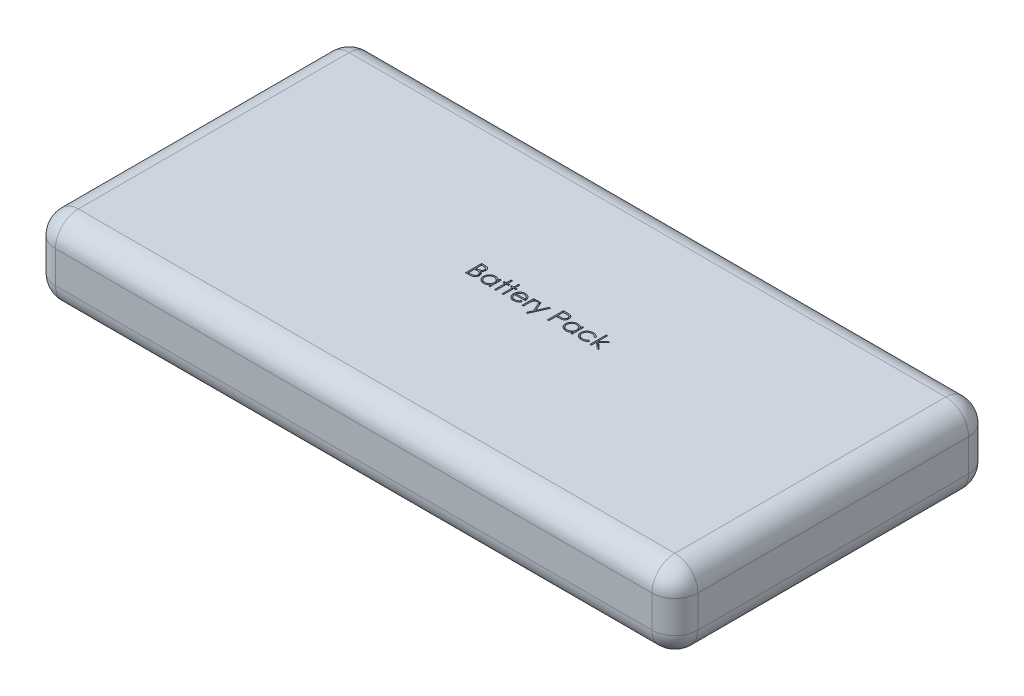
from build123d import *

# Parameters (mm, degrees)
SKETCH1_W           = 140
SKETCH1_H           = 69
BOSS_EXTRUDE1_DEPTH = 17
FILLET1_R           = 5
CUT_EXTRUDE1_DEPTH  = 1


with BuildPart() as part:
    # Sketch1 → Boss-Extrude1 (new body)
    with BuildSketch(Plane(origin=(0, 0, 0), x_dir=(1, 0, 0), z_dir=(0, 1, 0))):
        Rectangle(SKETCH1_W, SKETCH1_H)
    extrude(amount=BOSS_EXTRUDE1_DEPTH)

    # Fillet1
    fillet1_edges = [part.edges().sort_by_distance(p)[0] for p in [
        (-70, 17, 0),
        (0, 17, 34.5),
        (70, 17, 0),
        (0, 0, 34.5),
        (-70, 0, 0),
        (0, 0, -34.5),
        (70, 0, 0),
        (70, 8.5, 34.5),
        (-70, 8.5, 34.5),
        (-70, 8.5, -34.5),
        (70, 8.5, -34.5),
        (0, 17, -34.5),
    ]]
    fillet(fillet1_edges, radius=FILLET1_R)

    # Sketch2 → Cut-Extrude1 (cut)
    with BuildSketch(Plane(origin=(0, 17, 0), x_dir=(1, 0, 0), z_dir=(0, 1, 0))):
        with BuildLine():
            Line((-10.762481658, 4.15097288), (-10.07958903, 4.15097288))
            add(Edge.make_bspline(
                [(-10.07958903, 4.15097288), (-10.046160552, 4.15079713), (-9.981367841, 4.150456482), (-9.8871484, 4.145173351), (-9.798899589, 4.137969681), (-9.716595817, 4.126539588), (-9.640275114, 4.112747811), (-9.569707477, 4.096045995), (-9.505117305, 4.076019381), (-9.428004568, 4.0441731), (-9.340083907, 3.996849932), (-9.244885515, 3.926921367), (-9.163481275, 3.841388904), (-9.093294958, 3.744906248), (-9.037493839, 3.638770476), (-8.997124541, 3.525511288), (-8.971566666, 3.406589546), (-8.968938232, 3.324946368), (-8.967609863, 3.28368522)],
                knots=[0, 0, 0, 0, 0.00010027, 0.000194349, 0.000283026, 0.000365821, 0.000443519, 0.000515622, 0.000583254, 0.00064614, 0.000765662, 0.000881909, 0.000998927, 0.001118415, 0.001238844, 0.00135727, 0.001478274, 0.001601912, 0.001601912, 0.001601912, 0.001601912], degree=3))
            add(Edge.make_bspline(
                [(-8.967609863, 3.28368522), (-8.968703082, 3.245032664), (-8.970851359, 3.169076747), (-8.991394118, 3.057982638), (-9.023554787, 2.952231419), (-9.068260036, 2.852209034), (-9.126362032, 2.760175421), (-9.195220351, 2.675388155), (-9.278297153, 2.601437098), (-9.340540393, 2.560094195), (-9.372157139, 2.539093874)],
                knots=[0, 0, 0, 0, 0.000115857, 0.00022767, 0.000337672, 0.000446877, 0.000555233, 0.000663318, 0.000773539, 0.000887324, 0.000887324, 0.000887324, 0.000887324], degree=3))
            add(Edge.make_bspline(
                [(-9.372157139, 2.539093874), (-9.332396711, 2.523828875), (-9.256325164, 2.494623151), (-9.151639152, 2.442987687), (-9.061444307, 2.386825576), (-8.985047161, 2.325493726), (-8.919709506, 2.259384915), (-8.862656564, 2.187529801), (-8.81397519, 2.108991043), (-8.772262266, 2.024587508), (-8.73971351, 1.935181039), (-8.715337606, 1.841610263), (-8.701370157, 1.744210708), (-8.699382516, 1.677925329), (-8.698379094, 1.644462464)],
                knots=[0, 0, 0, 0, 0.000127722, 0.000244363, 0.000349599, 0.000445847, 0.000537565, 0.000627901, 0.000720503, 0.000814257, 0.000909859, 0.001005428, 0.001103887, 0.001204268, 0.001204268, 0.001204268, 0.001204268], degree=3))
            add(Edge.make_bspline(
                [(-8.698379094, 1.644462464), (-8.69935594, 1.610295592), (-8.701277912, 1.543071314), (-8.715457884, 1.444316179), (-8.739466991, 1.349941232), (-8.772538137, 1.25933605), (-8.815700452, 1.172675915), (-8.868228416, 1.089862651), (-8.93085998, 1.011728321), (-9.000922849, 0.937404697), (-9.080184994, 0.87057691), (-9.165700749, 0.811061203), (-9.258547069, 0.762115141), (-9.357199063, 0.72099912), (-9.462763379, 0.689591921), (-9.574765986, 0.667619347), (-9.693110288, 0.65281431), (-9.774320039, 0.651597106), (-9.815967235, 0.65097288)],
                knots=[0, 0, 0, 0, 0.000102481, 0.000201635, 0.000298562, 0.000394165, 0.000490425, 0.000588455, 0.000687769, 0.000790423, 0.000894381, 0.000998232, 0.001102369, 0.001208616, 0.001318415, 0.001432129, 0.001550749, 0.00167562, 0.00167562, 0.00167562, 0.00167562], degree=3))
            Line((-9.815967235, 0.65097288), (-10.762481658, 0.65097288))
            Line((-10.762481658, 0.65097288), (-10.762481658, 4.15097288))
        make_face()
        with BuildLine():
            Line((-10.448379094, 3.791998521), (-10.448379094, 2.67020365))
            Line((-10.448379094, 2.67020365), (-10.237341434, 2.67020365))
            add(Edge.make_bspline(
                [(-10.237341434, 2.67020365), (-10.206492638, 2.670603573), (-10.146886479, 2.671376305), (-10.060566583, 2.673589822), (-9.980441564, 2.679787866), (-9.906649731, 2.685984128), (-9.839307287, 2.696058716), (-9.778563426, 2.708050838), (-9.723464829, 2.720733744), (-9.659925283, 2.74230323), (-9.587852335, 2.774180906), (-9.511019231, 2.823652742), (-9.443284761, 2.882577095), (-9.386087574, 2.950568057), (-9.339276103, 3.025434243), (-9.306762388, 3.105981123), (-9.284715104, 3.190201255), (-9.282723572, 3.248019508), (-9.281712427, 3.277375124)],
                knots=[0, 0, 0, 0, 9.2559e-05, 0.000178842, 0.000258967, 0.000333616, 0.000400942, 0.000463093, 0.000519379, 0.000570374, 0.000664201, 0.000755025, 0.000843472, 0.000932526, 0.001020669, 0.001107124, 0.001192318, 0.001280185, 0.001280185, 0.001280185, 0.001280185], degree=3))
            add(Edge.make_bspline(
                [(-9.281712427, 3.277375124), (-9.282238608, 3.296800896), (-9.283270767, 3.334906668), (-9.29172407, 3.390456022), (-9.306091645, 3.442699774), (-9.324545938, 3.492353885), (-9.350334626, 3.537865735), (-9.38069809, 3.580808931), (-9.41738378, 3.619721049), (-9.459141093, 3.656090547), (-9.507149716, 3.688335075), (-9.561381007, 3.716575838), (-9.622568684, 3.739316615), (-9.689681539, 3.759232767), (-9.763752627, 3.773221061), (-9.84392718, 3.784874449), (-9.930861899, 3.790807191), (-9.991007002, 3.791592554), (-10.022097043, 3.791998521)],
                knots=[0, 0, 0, 0, 5.8261e-05, 0.000114285, 0.000168029, 0.000220632, 0.000272728, 0.000324483, 0.000378062, 0.000432741, 0.000490301, 0.000551137, 0.000615721, 0.000685833, 0.000760908, 0.00084162, 0.000928788, 0.00102206, 0.00102206, 0.00102206, 0.00102206], degree=3))
            Line((-10.022097043, 3.791998521), (-10.448379094, 3.791998521))
        make_face(mode=Mode.SUBTRACT)
        with BuildLine():
            Line((-10.448379094, 2.311229291), (-10.448379094, 1.009947239))
            Line((-10.448379094, 1.009947239), (-10.001063389, 1.009947239))
            add(Edge.make_bspline(
                [(-10.001063389, 1.009947239), (-9.969044463, 1.010330987), (-9.907332204, 1.011070609), (-9.818230974, 1.013485164), (-9.735647871, 1.01897744), (-9.659959735, 1.027623289), (-9.590349282, 1.037001738), (-9.527651579, 1.049613019), (-9.471358386, 1.06406198), (-9.406084078, 1.086396152), (-9.33258057, 1.121092623), (-9.253369713, 1.173406849), (-9.182943495, 1.235730157), (-9.123138236, 1.307861071), (-9.074125247, 1.386292398), (-9.038469792, 1.469437748), (-9.016478936, 1.555923276), (-9.013816766, 1.614889988), (-9.012481658, 1.644462464)],
                knots=[0, 0, 0, 0, 9.6064e-05, 0.000185151, 0.000267373, 0.000344257, 0.000413665, 0.000478015, 0.000536005, 0.000587888, 0.000684801, 0.000778918, 0.000871787, 0.000965866, 0.001059062, 0.00114827, 0.001236355, 0.001324974, 0.001324974, 0.001324974, 0.001324974], degree=3))
            add(Edge.make_bspline(
                [(-9.012481658, 1.644462464), (-9.012757763, 1.662955804), (-9.013305518, 1.699644186), (-9.021566133, 1.753560005), (-9.033580002, 1.805785879), (-9.049111436, 1.856463619), (-9.071730903, 1.904676995), (-9.098137448, 1.951379555), (-9.12909885, 1.996633034), (-9.177343016, 2.053845288), (-9.247515, 2.119762301), (-9.347221776, 2.184299803), (-9.460594074, 2.23634761), (-9.542821567, 2.258447086), (-9.585298165, 2.269863105)],
                knots=[0, 0, 0, 0, 5.5429e-05, 0.000109963, 0.000163198, 0.000216191, 0.000268588, 0.000322593, 0.000377046, 0.000432793, 0.000546889, 0.000664343, 0.000787646, 0.000919405, 0.000919405, 0.000919405, 0.000919405], degree=3))
            add(Edge.make_bspline(
                [(-9.585298165, 2.269863105), (-9.60232726, 2.273318189), (-9.639249853, 2.280809523), (-9.699457433, 2.288717227), (-9.768193302, 2.295762287), (-9.845616179, 2.300973444), (-9.93182402, 2.306359988), (-10.027000939, 2.308454809), (-10.130758254, 2.310954069), (-10.202750626, 2.311135203), (-10.240145921, 2.311229291)],
                knots=[0, 0, 0, 0, 5.2115e-05, 0.000112995, 0.000182062, 0.000259389, 0.000345767, 0.00044116, 0.000544948, 0.000657129, 0.000657129, 0.000657129, 0.000657129], degree=3))
            Line((-10.240145921, 2.311229291), (-10.448379094, 2.311229291))
        make_face(mode=Mode.SUBTRACT)
        with BuildLine():
            Line((-5.467609863, 3.208665188), (-5.467609863, 0.65097288))
            Line((-5.467609863, 0.65097288), (-5.781712427, 0.65097288))
            Line((-5.781712427, 0.65097288), (-5.781712427, 1.093380733))
            add(Edge.make_bspline(
                [(-5.781712427, 1.093380733), (-5.817131218, 1.053341139), (-5.886251433, 0.975203368), (-6.001692551, 0.873121195), (-6.124060729, 0.788742874), (-6.25276205, 0.720592958), (-6.387680294, 0.669400902), (-6.528516381, 0.633014743), (-6.675327762, 0.609620908), (-6.775580117, 0.607284886), (-6.826383902, 0.606101086)],
                knots=[0, 0, 0, 0, 0.000160263, 0.000312755, 0.000460949, 0.000605216, 0.000748578, 0.000892786, 0.001041028, 0.001193333, 0.001193333, 0.001193333, 0.001193333], degree=3))
            add(Edge.make_bspline(
                [(-6.826383902, 0.606101086), (-6.871551856, 0.607327458), (-6.96062506, 0.609745918), (-7.091654138, 0.628508222), (-7.217746387, 0.658638843), (-7.33902096, 0.700539733), (-7.454693105, 0.756120555), (-7.565753202, 0.822661803), (-7.671625894, 0.901902633), (-7.770697433, 0.992490661), (-7.861929433, 1.090885648), (-7.941990706, 1.195831195), (-8.008743786, 1.306873499), (-8.064563866, 1.422606653), (-8.107560211, 1.543921572), (-8.137533845, 1.67039874), (-8.156274292, 1.801888614), (-8.158691752, 1.891428137), (-8.159917556, 1.936830252)],
                knots=[0, 0, 0, 0, 0.000135464, 0.00026714, 0.000396211, 0.000523931, 0.000651257, 0.000780517, 0.000911767, 0.001047265, 0.00118272, 0.001313831, 0.001442491, 0.001570752, 0.001698704, 0.001827775, 0.001960146, 0.00209631, 0.00209631, 0.00209631, 0.00209631], degree=3))
            add(Edge.make_bspline(
                [(-8.159917556, 1.936830252), (-8.158664584, 1.981293956), (-8.156187527, 2.069196299), (-8.137734308, 2.198474997), (-8.106703299, 2.322993258), (-8.063155451, 2.442350201), (-8.007313496, 2.556690251), (-7.939385409, 2.666094276), (-7.859366285, 2.770863674), (-7.767113878, 2.8685349), (-7.667179107, 2.958755515), (-7.560270376, 3.03716456), (-7.449047095, 3.104881409), (-7.331784085, 3.158534885), (-7.21021698, 3.20194399), (-7.083263534, 3.231976958), (-6.951451955, 3.249674279), (-6.861961463, 3.252237043), (-6.816568197, 3.253536983)],
                knots=[0, 0, 0, 0, 0.000133363, 0.00026365, 0.000390846, 0.000517716, 0.000644083, 0.000771912, 0.000903449, 0.001038867, 0.001174416, 0.001306792, 0.001436052, 0.00156435, 0.001692963, 0.001822716, 0.001954992, 0.002091156, 0.002091156, 0.002091156, 0.002091156], degree=3))
            add(Edge.make_bspline(
                [(-6.816568197, 3.253536983), (-6.764368338, 3.252099231), (-6.662006878, 3.249279869), (-6.512278868, 3.225817141), (-6.37063439, 3.186178674), (-6.235980038, 3.132261176), (-6.108799352, 3.060612447), (-5.990296368, 2.970232486), (-5.879230885, 2.861691299), (-5.814850593, 2.778320854), (-5.781712427, 2.735407977)],
                knots=[0, 0, 0, 0, 0.00015654, 0.000306968, 0.000453261, 0.000596998, 0.000741098, 0.000889738, 0.001042937, 0.001205434, 0.001205434, 0.001205434, 0.001205434], degree=3))
            Line((-5.781712427, 2.735407977), (-5.781712427, 3.208665188))
            Line((-5.781712427, 3.208665188), (-5.467609863, 3.208665188))
        make_face()
        with BuildLine():
            add(Edge.make_bspline(
                [(-6.812361466, 2.939434419), (-6.858275804, 2.937800781), (-6.948903404, 2.93457624), (-7.081947406, 2.909402745), (-7.20926082, 2.867518151), (-7.330206894, 2.810236249), (-7.442875111, 2.738207513), (-7.543568782, 2.651086129), (-7.633111483, 2.551249115), (-7.708419747, 2.439147005), (-7.769810244, 2.318968914), (-7.812977276, 2.193344476), (-7.841446523, 2.064539498), (-7.844355044, 1.977176812), (-7.845814992, 1.933324643)],
                knots=[0, 0, 0, 0, 0.000137677, 0.000271753, 0.000404561, 0.000538791, 0.000672205, 0.000804452, 0.00093703, 0.001073348, 0.00120849, 0.001340643, 0.001470999, 0.001602378, 0.001602378, 0.001602378, 0.001602378], degree=3))
            add(Edge.make_bspline(
                [(-7.845814992, 1.933324643), (-7.843950098, 1.889734536), (-7.840227621, 1.80272518), (-7.813476927, 1.673744603), (-7.768597054, 1.548090561), (-7.707354991, 1.426829568), (-7.630668366, 1.314245467), (-7.541779714, 1.212505345), (-7.439829432, 1.125015757), (-7.326901925, 1.051778183), (-7.206293955, 0.992615662), (-7.079460023, 0.951450023), (-6.948784385, 0.924872242), (-6.859932051, 0.921767765), (-6.815165953, 0.92020365)],
                knots=[0, 0, 0, 0, 0.000130727, 0.000260941, 0.000393327, 0.000530037, 0.000667328, 0.000800955, 0.000934191, 0.001068956, 0.001203792, 0.001335934, 0.001468075, 0.001602253, 0.001602253, 0.001602253, 0.001602253], degree=3))
            add(Edge.make_bspline(
                [(-6.815165953, 0.92020365), (-6.76971945, 0.921863614), (-6.679330864, 0.925165117), (-6.545892156, 0.950446382), (-6.416397193, 0.992215181), (-6.292609965, 1.050114308), (-6.177293834, 1.121871663), (-6.073795956, 1.205878754), (-5.986279988, 1.303581939), (-5.912087378, 1.410958392), (-5.853911961, 1.528670388), (-5.811535902, 1.654004579), (-5.786481996, 1.786965327), (-5.783324267, 1.877829254), (-5.781712427, 1.92421006)],
                knots=[0, 0, 0, 0, 0.000136278, 0.000271043, 0.000405851, 0.000543552, 0.000679927, 0.000812429, 0.000941985, 0.001072088, 0.00120284, 0.001334538, 0.001467925, 0.001607002, 0.001607002, 0.001607002, 0.001607002], degree=3))
            add(Edge.make_bspline(
                [(-5.781712427, 1.92421006), (-5.782672084, 1.95954789), (-5.784560991, 2.029103924), (-5.798991561, 2.131231441), (-5.821946487, 2.228965167), (-5.854292657, 2.322407856), (-5.896783942, 2.411042872), (-5.948031707, 2.495506632), (-6.008937157, 2.575359843), (-6.078519853, 2.649502914), (-6.154685056, 2.717129377), (-6.235279596, 2.777493617), (-6.321258343, 2.82708239), (-6.41117538, 2.868123662), (-6.505186715, 2.900782811), (-6.604057335, 2.922570505), (-6.706736322, 2.937530826), (-6.776782377, 2.938793207), (-6.812361466, 2.939434419)],
                knots=[0, 0, 0, 0, 0.000105983, 0.000208608, 0.000308773, 0.00040678, 0.000504626, 0.000603105, 0.000702667, 0.00080535, 0.000907651, 0.001007914, 0.001106881, 0.00120477, 0.001304102, 0.001404791, 0.00150811, 0.001614764, 0.001614764, 0.001614764, 0.001614764], degree=3))
        make_face(mode=Mode.SUBTRACT)
        Polygon((-4.435558581, 4.24071647), (-4.121456017, 4.24071647), (-4.121456017, 3.208665188), (-3.672738068, 3.208665188), (-3.672738068, 2.894562624), (-4.121456017, 2.894562624), (-4.121456017, 0.65097288), (-4.435558581, 0.65097288), (-4.435558581, 2.894562624), (-4.88427653, 2.894562624), (-4.88427653, 3.208665188), (-4.435558581, 3.208665188), align=None)
        Polygon((-2.820173966, 4.24071647), (-2.506071402, 4.24071647), (-2.506071402, 3.208665188), (-2.057353453, 3.208665188), (-2.057353453, 2.894562624), (-2.506071402, 2.894562624), (-2.506071402, 0.65097288), (-2.820173966, 0.65097288), (-2.820173966, 2.894562624), (-3.268891915, 2.894562624), (-3.268891915, 3.208665188), (-2.820173966, 3.208665188), align=None)
        with BuildLine():
            Line((0.580266739, 1.458665188), (0.859313214, 1.312130733))
            add(Edge.make_bspline(
                [(0.859313214, 1.312130733), (0.837076618, 1.272687402), (0.79381301, 1.195946299), (0.719412262, 1.090514438), (0.641420189, 0.995666723), (0.556316221, 0.913937068), (0.466646542, 0.842685683), (0.371913888, 0.780347859), (0.27162507, 0.727229338), (0.165775345, 0.68247681), (0.053475794, 0.648067316), (-0.065545722, 0.623763095), (-0.191517218, 0.608739827), (-0.277863398, 0.606994686), (-0.322077011, 0.606101086)],
                knots=[0, 0, 0, 0, 0.000135759, 0.000264133, 0.000386579, 0.000503597, 0.000617365, 0.000729763, 0.000843304, 0.000957371, 0.001074023, 0.001195027, 0.001321389, 0.001453992, 0.001453992, 0.001453992, 0.001453992], degree=3))
            add(Edge.make_bspline(
                [(-0.322077011, 0.606101086), (-0.371218988, 0.607248261), (-0.46708075, 0.609486068), (-0.606620497, 0.628778532), (-0.737999915, 0.660250891), (-0.861211619, 0.704216432), (-0.975953871, 0.761643756), (-1.082454726, 0.831603238), (-1.181274252, 0.913735493), (-1.269298461, 1.008751936), (-1.348542344, 1.110433894), (-1.418468164, 1.216389778), (-1.476925595, 1.326353003), (-1.524478205, 1.439623527), (-1.56288307, 1.55548742), (-1.589649774, 1.674998888), (-1.605079522, 1.797834472), (-1.607443967, 1.880931808), (-1.608635504, 1.922807816)],
                knots=[0, 0, 0, 0, 0.000147371, 0.000287478, 0.000421649, 0.000552053, 0.000679042, 0.000805636, 0.000933558, 0.00106351, 0.001193382, 0.001319977, 0.001443869, 0.001566405, 0.001688128, 0.001809576, 0.001933238, 0.002058864, 0.002058864, 0.002058864, 0.002058864], degree=3))
            add(Edge.make_bspline(
                [(-1.608635504, 1.922807816), (-1.607576363, 1.962102647), (-1.605477285, 2.039979811), (-1.592246497, 2.155245356), (-1.568798204, 2.267273808), (-1.53662188, 2.376158256), (-1.495070634, 2.48171639), (-1.444238415, 2.584012454), (-1.384046037, 2.682937594), (-1.337573363, 2.745340728), (-1.31416435, 2.776774162)],
                knots=[0, 0, 0, 0, 0.000117891, 0.000233644, 0.000347498, 0.000460856, 0.000573868, 0.000687374, 0.000803169, 0.000920699, 0.000920699, 0.000920699, 0.000920699], degree=3))
            add(Edge.make_bspline(
                [(-1.31416435, 2.776774162), (-1.282456668, 2.814643033), (-1.220045721, 2.889181183), (-1.114489366, 2.987119509), (-1.000189169, 3.069163284), (-0.878577543, 3.13717042), (-0.748241069, 3.188844067), (-0.610931778, 3.227351649), (-0.465086192, 3.24892966), (-0.365380971, 3.251977494), (-0.314364671, 3.253536983)],
                knots=[0, 0, 0, 0, 0.000148071, 0.000291452, 0.00043058, 0.000569298, 0.000708346, 0.00085021, 0.000996268, 0.001149307, 0.001149307, 0.001149307, 0.001149307], degree=3))
            add(Edge.make_bspline(
                [(-0.314364671, 3.253536983), (-0.261917066, 3.252182934), (-0.15902682, 3.249526599), (-0.008994699, 3.224900265), (0.132966018, 3.185847711), (0.266798522, 3.13069392), (0.392516383, 3.059534369), (0.509302432, 2.971392527), (0.619153945, 2.86897444), (0.683062524, 2.79021123), (0.715583246, 2.750131534)],
                knots=[0, 0, 0, 0, 0.000157241, 0.00030847, 0.000454763, 0.000598116, 0.000741606, 0.000886879, 0.001036172, 0.001190853, 0.001190853, 0.001190853, 0.001190853], degree=3))
            add(Edge.make_bspline(
                [(0.715583246, 2.750131534), (0.737710184, 2.719927953), (0.781816777, 2.659721834), (0.837063877, 2.561550677), (0.885021272, 2.458840083), (0.923354233, 2.349929786), (0.954393734, 2.236110205), (0.976850553, 2.116567661), (0.990020172, 1.991337749), (0.992608869, 1.906011194), (0.993928598, 1.862511342)],
                knots=[0, 0, 0, 0, 0.000112234, 0.000223721, 0.000337279, 0.000451932, 0.000569628, 0.000690912, 0.000816421, 0.00094695, 0.00094695, 0.00094695, 0.00094695], degree=3))
            Line((0.993928598, 1.862511342), (-1.29453294, 1.862511342))
            add(Edge.make_bspline(
                [(-1.29453294, 1.862511342), (-1.292993334, 1.828810878), (-1.28996576, 1.762540274), (-1.275850617, 1.665569491), (-1.253601843, 1.573196149), (-1.22233278, 1.486113107), (-1.184465935, 1.403182979), (-1.138080218, 1.325020942), (-1.082740664, 1.251983012), (-1.021014965, 1.183415875), (-0.95230787, 1.122355113), (-0.880025122, 1.067703337), (-0.803131557, 1.02189774), (-0.722233474, 0.984717851), (-0.637461689, 0.955611535), (-0.548789494, 0.935743714), (-0.456391377, 0.922436607), (-0.393405643, 0.920956942), (-0.361339831, 0.92020365)],
                knots=[0, 0, 0, 0, 0.000101159, 0.000198924, 0.000293472, 0.000385722, 0.000476069, 0.000566611, 0.000657757, 0.000750573, 0.000842919, 0.000933083, 0.001022062, 0.001110842, 0.001199752, 0.001290403, 0.001383113, 0.001479259, 0.001479259, 0.001479259, 0.001479259], degree=3))
            add(Edge.make_bspline(
                [(-0.361339831, 0.92020365), (-0.329988684, 0.920811706), (-0.267781993, 0.922018207), (-0.175141135, 0.933750118), (-0.084001608, 0.952720394), (0.005259375, 0.978610384), (0.090830221, 1.010187236), (0.170075771, 1.048290094), (0.242955987, 1.09043984), (0.311072953, 1.138649516), (0.377143947, 1.197657703), (0.442686433, 1.271293424), (0.512963087, 1.358380951), (0.556952679, 1.423926617), (0.580266739, 1.458665188)],
                knots=[0, 0, 0, 0, 9.4016e-05, 0.000186545, 0.000279636, 0.000373054, 0.000465125, 0.000552934, 0.000636508, 0.000717442, 0.000802858, 0.000901616, 0.001012865, 0.001138311, 0.001138311, 0.001138311, 0.001138311], degree=3))
        make_face()
        with BuildLine():
            add(Edge.make_bspline(
                [(0.679826034, 2.176613906), (0.66832941, 2.21827678), (0.646202108, 2.2984644), (0.599965744, 2.409505291), (0.547894203, 2.508193192), (0.486272472, 2.593772825), (0.416453746, 2.669776338), (0.335808563, 2.736194923), (0.24537267, 2.795612374), (0.145613529, 2.845764874), (0.039971744, 2.888454732), (-0.070634448, 2.917079848), (-0.183492236, 2.93668939), (-0.259826522, 2.938515499), (-0.29823887, 2.939434419)],
                knots=[0, 0, 0, 0, 0.000129543, 0.000249328, 0.000360065, 0.000463575, 0.000564789, 0.000668832, 0.000776175, 0.000888744, 0.001003316, 0.001117263, 0.001230914, 0.001346035, 0.001346035, 0.001346035, 0.001346035], degree=3))
            add(Edge.make_bspline(
                [(-0.29823887, 2.939434419), (-0.329588308, 2.938822747), (-0.391559557, 2.937613601), (-0.482860625, 2.926143472), (-0.570540324, 2.907183627), (-0.655245612, 2.88121867), (-0.73586648, 2.846610068), (-0.814061249, 2.806026841), (-0.887841645, 2.756485258), (-0.93398294, 2.718726403), (-0.957293357, 2.699650765)],
                knots=[0, 0, 0, 0, 9.4016e-05, 0.000185849, 0.000275511, 0.000362884, 0.000451173, 0.00053836, 0.000626838, 0.000717174, 0.000717174, 0.000717174, 0.000717174], degree=3))
            add(Edge.make_bspline(
                [(-0.957293357, 2.699650765), (-0.973986639, 2.684556449), (-1.007769773, 2.654009233), (-1.052910295, 2.601380027), (-1.096130767, 2.544628465), (-1.13546442, 2.48158334), (-1.171542006, 2.412962561), (-1.205301984, 2.339344926), (-1.235688396, 2.260171796), (-1.252784506, 2.204999356), (-1.261580216, 2.176613906)],
                knots=[0, 0, 0, 0, 6.7454e-05, 0.00013651, 0.000207604, 0.000281328, 0.000359112, 0.000440057, 0.000524171, 0.000613305, 0.000613305, 0.000613305, 0.000613305], degree=3))
            Line((-1.261580216, 2.176613906), (0.679826034, 2.176613906))
        make_face(mode=Mode.SUBTRACT)
        with BuildLine():
            Line((1.532390137, 3.208665188), (1.846492701, 3.208665188))
            Line((1.846492701, 3.208665188), (1.846492701, 2.832162784))
            add(Edge.make_bspline(
                [(1.846492701, 2.832162784), (1.86968146, 2.867218613), (1.91402978, 2.934262612), (1.98774271, 3.022931913), (2.063246041, 3.096346959), (2.140901228, 3.154850478), (2.221279328, 3.198663597), (2.30261628, 3.230756632), (2.38619175, 3.249733947), (2.442353674, 3.252267606), (2.470491098, 3.253536983)],
                knots=[0, 0, 0, 0, 0.000126023, 0.000241017, 0.000345147, 0.000441342, 0.00053171, 0.000618946, 0.000702978, 0.000787349, 0.000787349, 0.000787349, 0.000787349], degree=3))
            add(Edge.make_bspline(
                [(2.470491098, 3.253536983), (2.492317425, 3.252346456), (2.53722651, 3.249896871), (2.6052091, 3.232686046), (2.675252552, 3.205208023), (2.720394939, 3.179367801), (2.743928598, 3.165896759)],
                knots=[0, 0, 0, 0, 6.5445e-05, 0.000134658, 0.00020926, 0.000290509, 0.000290509, 0.000290509, 0.000290509], degree=3))
            Line((2.743928598, 3.165896759), (2.571452637, 2.893861502))
            add(Edge.make_bspline(
                [(2.571452637, 2.893861502), (2.556343616, 2.900601768), (2.527663801, 2.913396084), (2.485709235, 2.928538094), (2.447027898, 2.93745401), (2.42238434, 2.938804727), (2.410895746, 2.939434419)],
                knots=[0, 0, 0, 0, 4.9621e-05, 9.4191e-05, 0.00013366, 0.000168129, 0.000168129, 0.000168129, 0.000168129], degree=3))
            add(Edge.make_bspline(
                [(2.410895746, 2.939434419), (2.385690012, 2.937754381), (2.334277622, 2.934327592), (2.258793123, 2.907388784), (2.185545917, 2.863863544), (2.127374255, 2.815592433), (2.082332002, 2.769044635), (2.050191777, 2.728396232), (2.02070903, 2.682817601), (1.992538809, 2.633087917), (1.966872515, 2.578358071), (1.942917846, 2.519174858), (1.921258983, 2.455469729), (1.908908739, 2.411087209), (1.902582444, 2.388352688)],
                knots=[0, 0, 0, 0, 7.549e-05, 0.000153978, 0.000237553, 0.000330197, 0.000379784, 0.000431685, 0.000485357, 0.000542493, 0.000603021, 0.000666557, 0.00073396, 0.000804745, 0.000804745, 0.000804745, 0.000804745], degree=3))
            add(Edge.make_bspline(
                [(1.902582444, 2.388352688), (1.897850051, 2.368075515), (1.887368159, 2.323163116), (1.877176621, 2.247814591), (1.867107103, 2.158790932), (1.860010485, 2.05584434), (1.853432443, 1.939231896), (1.849722361, 1.80877595), (1.84661922, 1.664342599), (1.846536153, 1.563368246), (1.846492701, 1.510548201)],
                knots=[0, 0, 0, 0, 6.2435e-05, 0.000138289, 0.000227871, 0.000331224, 0.000447781, 0.000578258, 0.000722716, 0.000881171, 0.000881171, 0.000881171, 0.000881171], degree=3))
            Line((1.846492701, 1.510548201), (1.846492701, 0.65097288))
            Line((1.846492701, 0.65097288), (1.532390137, 0.65097288))
            Line((1.532390137, 0.65097288), (1.532390137, 3.208665188))
        make_face()
        Polygon((2.788800393, 3.208665188), (3.12744222, 3.208665188), (3.993327637, 1.249730893), (4.872534367, 3.208665188), (5.211877316, 3.208665188), (3.641364496, -0.291334812), (3.302021547, -0.291334812), (3.822955041, 0.869021759), align=None)
        with BuildLine():
            Line((7.051620906, 4.15097288), (7.738019143, 4.15097288))
            add(Edge.make_bspline(
                [(7.738019143, 4.15097288), (7.785230049, 4.150920984), (7.875688242, 4.150821549), (8.005403298, 4.147806803), (8.123213029, 4.143780111), (8.22886341, 4.138198218), (8.322679508, 4.131601627), (8.404236808, 4.122349588), (8.474176364, 4.112689292), (8.516082814, 4.102867886), (8.535194624, 4.098388746)],
                knots=[0, 0, 0, 0, 0.000141628, 0.000271366, 0.00038923, 0.000495248, 0.00058876, 0.000671296, 0.000741499, 0.00080036, 0.00080036, 0.00080036, 0.00080036], degree=3))
            add(Edge.make_bspline(
                [(8.535194624, 4.098388746), (8.559388158, 4.091766796), (8.607205135, 4.078678934), (8.676106178, 4.052465211), (8.741660023, 4.021383046), (8.804091582, 3.985959106), (8.862633665, 3.944673542), (8.918159706, 3.899199924), (8.970179686, 3.848488355), (9.018401078, 3.793107615), (9.062685876, 3.733987406), (9.100815558, 3.670245176), (9.132742785, 3.602953872), (9.160126057, 3.532160301), (9.179834511, 3.457269978), (9.194681411, 3.378803265), (9.204105039, 3.296768575), (9.2050076, 3.240708707), (9.20546706, 3.212170797)],
                knots=[0, 0, 0, 0, 7.5216e-05, 0.00014866, 0.000220794, 0.000292713, 0.000363707, 0.000435434, 0.000507823, 0.000581364, 0.000655543, 0.000729131, 0.000803767, 0.000878771, 0.000956497, 0.001035702, 0.001118238, 0.001203821, 0.001203821, 0.001203821, 0.001203821], degree=3))
            add(Edge.make_bspline(
                [(9.20546706, 3.212170797), (9.205045635, 3.18339302), (9.204221089, 3.127087356), (9.194324804, 3.044714568), (9.180994612, 2.965996178), (9.16049756, 2.891106728), (9.133651887, 2.820490957), (9.102159834, 2.753069725), (9.064176303, 2.689990053), (9.020531474, 2.631022936), (8.971979879, 2.576113023), (8.918726941, 2.525658229), (8.860987649, 2.47995389), (8.798945501, 2.438897547), (8.731995652, 2.403441267), (8.661153498, 2.371683962), (8.585803282, 2.345012902), (8.533660768, 2.33098284), (8.507149752, 2.323849483)],
                knots=[0, 0, 0, 0, 8.6284e-05, 0.00016882, 0.000248587, 0.000325638, 0.000401297, 0.000474998, 0.000548586, 0.000621785, 0.0006948, 0.0007682, 0.000841564, 0.000915458, 0.000991056, 0.00106858, 0.00114819, 0.001230532, 0.001230532, 0.001230532, 0.001230532], degree=3))
            add(Edge.make_bspline(
                [(8.507149752, 2.323849483), (8.485222418, 2.319186502), (8.437167391, 2.308967308), (8.358024669, 2.297558851), (8.265879283, 2.28782125), (8.160857003, 2.280520113), (8.043052098, 2.274269744), (7.91240084, 2.26930165), (7.768646763, 2.266571796), (7.668375519, 2.266431004), (7.616023951, 2.266357496)],
                knots=[0, 0, 0, 0, 6.7238e-05, 0.000147357, 0.000239727, 0.000345177, 0.000463135, 0.000593636, 0.000737393, 0.000894446, 0.000894446, 0.000894446, 0.000894446], degree=3))
            Line((7.616023951, 2.266357496), (7.36572347, 2.266357496))
            Line((7.36572347, 2.266357496), (7.36572347, 0.65097288))
            Line((7.36572347, 0.65097288), (7.051620906, 0.65097288))
            Line((7.051620906, 0.65097288), (7.051620906, 4.15097288))
        make_face()
        with BuildLine():
            Line((7.36572347, 3.791998521), (7.36572347, 2.625331855))
            Line((7.36572347, 2.625331855), (7.978503919, 2.617619515))
            add(Edge.make_bspline(
                [(7.978503919, 2.617619515), (8.008423845, 2.617604051), (8.066183644, 2.617574199), (8.149619868, 2.621559423), (8.227029155, 2.626159955), (8.29817373, 2.632895879), (8.363085665, 2.642417136), (8.421873194, 2.652028874), (8.474080477, 2.665934237), (8.535179678, 2.684657306), (8.603263026, 2.716589922), (8.677330574, 2.762939812), (8.740101161, 2.82202052), (8.794419458, 2.888448351), (8.837525335, 2.962347481), (8.869081328, 3.041416417), (8.887622485, 3.124844267), (8.890108679, 3.181932406), (8.891364496, 3.210768553)],
                knots=[0, 0, 0, 0, 8.9746e-05, 0.000173253, 0.000250533, 0.00032239, 0.000387534, 0.00044736, 0.000500926, 0.000549486, 0.000638903, 0.000725641, 0.000810488, 0.000896226, 0.000982324, 0.00106604, 0.001150757, 0.001237226, 0.001237226, 0.001237226, 0.001237226], degree=3))
            add(Edge.make_bspline(
                [(8.891364496, 3.210768553), (8.890101849, 3.238907067), (8.887591864, 3.294842949), (8.868936001, 3.37682171), (8.837586687, 3.455057414), (8.794130093, 3.528030499), (8.741388963, 3.594219303), (8.68008962, 3.65171643), (8.610376358, 3.697938133), (8.545528127, 3.727771415), (8.487926941, 3.74598669), (8.437894981, 3.758731531), (8.381404307, 3.768907137), (8.318436527, 3.77714664), (8.249479693, 3.784200101), (8.173941379, 3.788986078), (8.092107735, 3.791787534), (8.035297164, 3.79192649), (8.005847669, 3.791998521)],
                knots=[0, 0, 0, 0, 8.4371e-05, 0.000167719, 0.000250783, 0.000336277, 0.000421575, 0.000503926, 0.000587348, 0.000671427, 0.000717102, 0.000768457, 0.000826213, 0.000889178, 0.000958942, 0.001034123, 0.001116202, 0.001204546, 0.001204546, 0.001204546, 0.001204546], degree=3))
            Line((8.005847669, 3.791998521), (7.36572347, 3.791998521))
        make_face(mode=Mode.SUBTRACT)
        with BuildLine():
            Line((12.436236291, 3.208665188), (12.436236291, 0.65097288))
            Line((12.436236291, 0.65097288), (12.122133726, 0.65097288))
            Line((12.122133726, 0.65097288), (12.122133726, 1.093380733))
            add(Edge.make_bspline(
                [(12.122133726, 1.093380733), (12.086714936, 1.053341139), (12.017594721, 0.975203368), (11.902153603, 0.873121195), (11.779785425, 0.788742874), (11.651084104, 0.720592958), (11.51616586, 0.669400902), (11.375329773, 0.633014743), (11.228518392, 0.609620908), (11.128266037, 0.607284886), (11.077462252, 0.606101086)],
                knots=[0, 0, 0, 0, 0.000160263, 0.000312755, 0.000460949, 0.000605216, 0.000748578, 0.000892786, 0.001041028, 0.001193333, 0.001193333, 0.001193333, 0.001193333], degree=3))
            add(Edge.make_bspline(
                [(11.077462252, 0.606101086), (11.032294298, 0.607327458), (10.943221093, 0.609745918), (10.812192016, 0.628508222), (10.686099767, 0.658638843), (10.564825194, 0.700539733), (10.449153049, 0.756120555), (10.338092952, 0.822661803), (10.23222026, 0.901902633), (10.133148721, 0.992490661), (10.041916721, 1.090885648), (9.961855448, 1.195831195), (9.895102368, 1.306873499), (9.839282287, 1.422606653), (9.796285943, 1.543921572), (9.766312309, 1.67039874), (9.747571862, 1.801888614), (9.745154401, 1.891428137), (9.743928598, 1.936830252)],
                knots=[0, 0, 0, 0, 0.000135464, 0.00026714, 0.000396211, 0.000523931, 0.000651257, 0.000780517, 0.000911767, 0.001047265, 0.00118272, 0.001313831, 0.001442491, 0.001570752, 0.001698704, 0.001827775, 0.001960146, 0.00209631, 0.00209631, 0.00209631, 0.00209631], degree=3))
            add(Edge.make_bspline(
                [(9.743928598, 1.936830252), (9.74518157, 1.981293956), (9.747658626, 2.069196299), (9.766111846, 2.198474997), (9.797142855, 2.322993258), (9.840690703, 2.442350201), (9.896532658, 2.556690251), (9.964460745, 2.666094276), (10.044479869, 2.770863674), (10.136732276, 2.8685349), (10.236667046, 2.958755515), (10.343575777, 3.03716456), (10.454799059, 3.104881409), (10.572062069, 3.158534885), (10.693629174, 3.20194399), (10.82058262, 3.231976958), (10.952394198, 3.249674279), (11.041884691, 3.252237043), (11.087277957, 3.253536983)],
                knots=[0, 0, 0, 0, 0.000133363, 0.00026365, 0.000390846, 0.000517716, 0.000644083, 0.000771912, 0.000903449, 0.001038867, 0.001174416, 0.001306792, 0.001436052, 0.00156435, 0.001692963, 0.001822716, 0.001954992, 0.002091156, 0.002091156, 0.002091156, 0.002091156], degree=3))
            add(Edge.make_bspline(
                [(11.087277957, 3.253536983), (11.139477816, 3.252099231), (11.241839276, 3.249279869), (11.391567286, 3.225817141), (11.533211763, 3.186178674), (11.667866115, 3.132261176), (11.795046802, 3.060612447), (11.913549786, 2.970232486), (12.024615269, 2.861691299), (12.088995561, 2.778320854), (12.122133726, 2.735407977)],
                knots=[0, 0, 0, 0, 0.00015654, 0.000306968, 0.000453261, 0.000596998, 0.000741098, 0.000889738, 0.001042937, 0.001205434, 0.001205434, 0.001205434, 0.001205434], degree=3))
            Line((12.122133726, 2.735407977), (12.122133726, 3.208665188))
            Line((12.122133726, 3.208665188), (12.436236291, 3.208665188))
        make_face()
        with BuildLine():
            add(Edge.make_bspline(
                [(11.091484688, 2.939434419), (11.04557035, 2.937800781), (10.95494275, 2.93457624), (10.821898748, 2.909402745), (10.694585334, 2.867518151), (10.57363926, 2.810236249), (10.460971043, 2.738207513), (10.360277372, 2.651086129), (10.270734671, 2.551249115), (10.195426407, 2.439147005), (10.13403591, 2.318968914), (10.090868878, 2.193344476), (10.06239963, 2.064539498), (10.05949111, 1.977176812), (10.058031162, 1.933324643)],
                knots=[0, 0, 0, 0, 0.000137677, 0.000271753, 0.000404561, 0.000538791, 0.000672205, 0.000804452, 0.00093703, 0.001073348, 0.00120849, 0.001340643, 0.001470999, 0.001602378, 0.001602378, 0.001602378, 0.001602378], degree=3))
            add(Edge.make_bspline(
                [(10.058031162, 1.933324643), (10.059896056, 1.889734536), (10.063618533, 1.80272518), (10.090369227, 1.673744603), (10.1352491, 1.548090561), (10.196491163, 1.426829568), (10.273177788, 1.314245467), (10.36206644, 1.212505345), (10.464016722, 1.125015757), (10.576944229, 1.051778183), (10.697552199, 0.992615662), (10.824386131, 0.951450023), (10.955061769, 0.924872242), (11.043914103, 0.921767765), (11.088680201, 0.92020365)],
                knots=[0, 0, 0, 0, 0.000130727, 0.000260941, 0.000393327, 0.000530037, 0.000667328, 0.000800955, 0.000934191, 0.001068956, 0.001203792, 0.001335934, 0.001468075, 0.001602253, 0.001602253, 0.001602253, 0.001602253], degree=3))
            add(Edge.make_bspline(
                [(11.088680201, 0.92020365), (11.134126704, 0.921863614), (11.22451529, 0.925165117), (11.357953998, 0.950446382), (11.487448961, 0.992215181), (11.611236189, 1.050114308), (11.72655232, 1.121871663), (11.830050198, 1.205878754), (11.917566166, 1.303581939), (11.991758776, 1.410958392), (12.049934193, 1.528670388), (12.092310252, 1.654004579), (12.117364158, 1.786965327), (12.120521887, 1.877829254), (12.122133726, 1.92421006)],
                knots=[0, 0, 0, 0, 0.000136278, 0.000271043, 0.000405851, 0.000543552, 0.000679927, 0.000812429, 0.000941985, 0.001072088, 0.00120284, 0.001334538, 0.001467925, 0.001607002, 0.001607002, 0.001607002, 0.001607002], degree=3))
            add(Edge.make_bspline(
                [(12.122133726, 1.92421006), (12.12117407, 1.95954789), (12.119285163, 2.029103924), (12.104854593, 2.131231441), (12.081899667, 2.228965167), (12.049553497, 2.322407856), (12.007062212, 2.411042872), (11.955814446, 2.495506632), (11.894908997, 2.575359843), (11.825326301, 2.649502914), (11.749161098, 2.717129377), (11.668566557, 2.777493617), (11.58258781, 2.82708239), (11.492670773, 2.868123662), (11.398659439, 2.900782811), (11.299788819, 2.922570505), (11.197109832, 2.937530826), (11.127063777, 2.938793207), (11.091484688, 2.939434419)],
                knots=[0, 0, 0, 0, 0.000105983, 0.000208608, 0.000308773, 0.00040678, 0.000504626, 0.000603105, 0.000702667, 0.00080535, 0.000907651, 0.001007914, 0.001106881, 0.00120477, 0.001304102, 0.001404791, 0.00150811, 0.001614764, 0.001614764, 0.001614764, 0.001614764], degree=3))
        make_face(mode=Mode.SUBTRACT)
        with BuildLine():
            Line((15.667005521, 2.654077848), (15.404084848, 2.49071647))
            add(Edge.make_bspline(
                [(15.404084848, 2.49071647), (15.375254983, 2.526544864), (15.318508288, 2.597066974), (15.219969051, 2.688076908), (15.114957637, 2.766243949), (15.001679589, 2.8299477), (14.880293789, 2.879169151), (14.751278938, 2.913999356), (14.614653433, 2.935703599), (14.520988234, 2.938170436), (14.472995105, 2.939434419)],
                knots=[0, 0, 0, 0, 0.0001378, 0.000271237, 0.000401088, 0.000529797, 0.000659994, 0.000793002, 0.000929944, 0.001073845, 0.001073845, 0.001073845, 0.001073845], degree=3))
            add(Edge.make_bspline(
                [(14.472995105, 2.939434419), (14.434636148, 2.938377577), (14.359089225, 2.936296155), (14.248183072, 2.923285661), (14.142540719, 2.899643653), (14.04150001, 2.868492696), (13.945779591, 2.826742406), (13.855128673, 2.77593265), (13.768743183, 2.71688261), (13.689126441, 2.648472065), (13.616297434, 2.574073397), (13.55319852, 2.494319702), (13.498261587, 2.41159981), (13.455155631, 2.323848068), (13.41988046, 2.233072015), (13.39667374, 2.137558159), (13.381209045, 2.038530152), (13.379439716, 1.971011812), (13.378543983, 1.936830252)],
                knots=[0, 0, 0, 0, 0.000115089, 0.000226664, 0.000334347, 0.000439455, 0.000543394, 0.000646972, 0.000750824, 0.000856758, 0.000961376, 0.00106266, 0.001161449, 0.00125865, 0.001355399, 0.001453007, 0.001552955, 0.001655437, 0.001655437, 0.001655437, 0.001655437], degree=3))
            add(Edge.make_bspline(
                [(13.378543983, 1.936830252), (13.380323235, 1.892061041), (13.383857766, 1.803125845), (13.411559225, 1.671847744), (13.456903633, 1.544924053), (13.518961483, 1.423255916), (13.597438618, 1.310661761), (13.689611181, 1.209678306), (13.795530264, 1.122262278), (13.914262595, 1.049789753), (14.043020338, 0.991528386), (14.180410443, 0.950021053), (14.325310224, 0.92496868), (14.424516971, 0.921812737), (14.47509847, 0.92020365)],
                knots=[0, 0, 0, 0, 0.000134224, 0.00026664, 0.000400581, 0.000537609, 0.000675117, 0.000811087, 0.000946551, 0.001085679, 0.001227203, 0.001369372, 0.001515181, 0.001666857, 0.001666857, 0.001666857, 0.001666857], degree=3))
            add(Edge.make_bspline(
                [(14.47509847, 0.92020365), (14.521453654, 0.921503147), (14.612553893, 0.924057004), (14.745721178, 0.945585967), (14.872501089, 0.980829601), (14.992889119, 1.029977251), (15.106665285, 1.093504767), (15.21309446, 1.171863937), (15.314294399, 1.262800538), (15.373791375, 1.333118509), (15.404084848, 1.368921598)],
                knots=[0, 0, 0, 0, 0.000138999, 0.00027317, 0.000403475, 0.000533023, 0.000662344, 0.000793326, 0.000928824, 0.001069379, 0.001069379, 0.001069379, 0.001069379], degree=3))
            Line((15.404084848, 1.368921598), (15.667005521, 1.196445637))
            add(Edge.make_bspline(
                [(15.667005521, 1.196445637), (15.651417819, 1.17355491), (15.620294152, 1.127849433), (15.568266527, 1.063405317), (15.512146695, 1.003083634), (15.452153598, 0.946965244), (15.389070588, 0.893707225), (15.320742679, 0.84585565), (15.249373067, 0.800720828), (15.17412391, 0.760107956), (15.095773212, 0.723601634), (15.014431222, 0.692210463), (14.930451409, 0.665240357), (14.843735033, 0.643803011), (14.754111135, 0.626692172), (14.6618115, 0.615338471), (14.566867919, 0.606863189), (14.502695767, 0.606357323), (14.470190617, 0.606101086)],
                knots=[0, 0, 0, 0, 8.3056e-05, 0.000165835, 0.000248187, 0.000330026, 0.000412165, 0.000495625, 0.000580051, 0.000665384, 0.00075196, 0.000839196, 0.00092678, 0.001016395, 0.001107013, 0.001200326, 0.001295291, 0.001392769, 0.001392769, 0.001392769, 0.001392769], degree=3))
            add(Edge.make_bspline(
                [(14.470190617, 0.606101086), (14.420579734, 0.606992365), (14.323342042, 0.60873928), (14.181019534, 0.627947756), (14.045005867, 0.656905372), (13.915347509, 0.698469106), (13.792024275, 0.751973881), (13.675151156, 0.817330796), (13.565115138, 0.895082586), (13.463004355, 0.983845355), (13.369222909, 1.080085996), (13.288696719, 1.183935914), (13.218851448, 1.291576962), (13.162763905, 1.405386488), (13.118116979, 1.52385186), (13.087612146, 1.6479221), (13.067882409, 1.776574354), (13.065599029, 1.864307236), (13.064441419, 1.90878538)],
                knots=[0, 0, 0, 0, 0.000148744, 0.000291539, 0.000430022, 0.000565498, 0.000699266, 0.000832672, 0.000966504, 0.001102706, 0.001238073, 0.00136893, 0.00149632, 0.001622368, 0.001748823, 0.001875338, 0.002005032, 0.002138395, 0.002138395, 0.002138395, 0.002138395], degree=3))
            add(Edge.make_bspline(
                [(13.064441419, 1.90878538), (13.064882435, 1.938963815), (13.065759689, 1.998993702), (13.075821616, 2.088088769), (13.088820089, 2.175997314), (13.110845827, 2.261605034), (13.136286458, 2.346210324), (13.16876199, 2.428793425), (13.206857385, 2.509738098), (13.250109332, 2.588835827), (13.298798077, 2.664785367), (13.352679311, 2.736539032), (13.409723647, 2.804958797), (13.472599759, 2.867682558), (13.538639413, 2.927218749), (13.609710988, 2.981976873), (13.68540684, 3.032117864), (13.764590163, 3.07856888), (13.847214874, 3.119928315), (13.932781544, 3.155561553), (14.020774573, 3.186014129), (14.111334718, 3.210123048), (14.203860891, 3.230340471), (14.299082229, 3.243058318), (14.396634451, 3.25204459), (14.462690474, 3.253035383), (14.496132124, 3.253536983)],
                knots=[0, 0, 0, 0, 9.0488e-05, 0.000179996, 0.000268751, 0.000356836, 0.000444879, 0.000533675, 0.000622751, 0.00071312, 0.000803944, 0.000893127, 0.000982181, 0.001070925, 0.00115931, 0.001248782, 0.001339788, 0.001431538, 0.001524036, 0.001616746, 0.001709427, 0.001803141, 0.001897749, 0.001993333, 0.002091151, 0.002191451, 0.002191451, 0.002191451, 0.002191451], degree=3))
            add(Edge.make_bspline(
                [(14.496132124, 3.253536983), (14.538012232, 3.252615092), (14.621563112, 3.250775918), (14.745503818, 3.235297266), (14.867619012, 3.211960849), (14.985766116, 3.177388019), (15.09851263, 3.135524364), (15.20404808, 3.088511649), (15.299888184, 3.033917046), (15.387815773, 2.974196932), (15.467995291, 2.906836026), (15.541249783, 2.831029068), (15.609081432, 2.747170589), (15.647538144, 2.685364858), (15.667005521, 2.654077848)],
                knots=[0, 0, 0, 0, 0.000125597, 0.000250566, 0.00037418, 0.000498223, 0.000619345, 0.000734815, 0.00084439, 0.000949794, 0.001053299, 0.001157917, 0.001265662, 0.001376119, 0.001376119, 0.001376119, 0.001376119], degree=3))
        make_face()
        Polygon((16.29521065, 4.24071647), (16.609313214, 4.24071647), (16.609313214, 2.165395957), (17.773175393, 3.208665188), (18.224697829, 3.208665188), (16.874337252, 1.997126727), (18.359313214, 0.65097288), (17.9084919, 0.65097288), (16.609313214, 1.829558618), (16.609313214, 0.65097288), (16.29521065, 0.65097288), align=None)
    extrude(amount=-CUT_EXTRUDE1_DEPTH, mode=Mode.SUBTRACT)


solid = part.part
